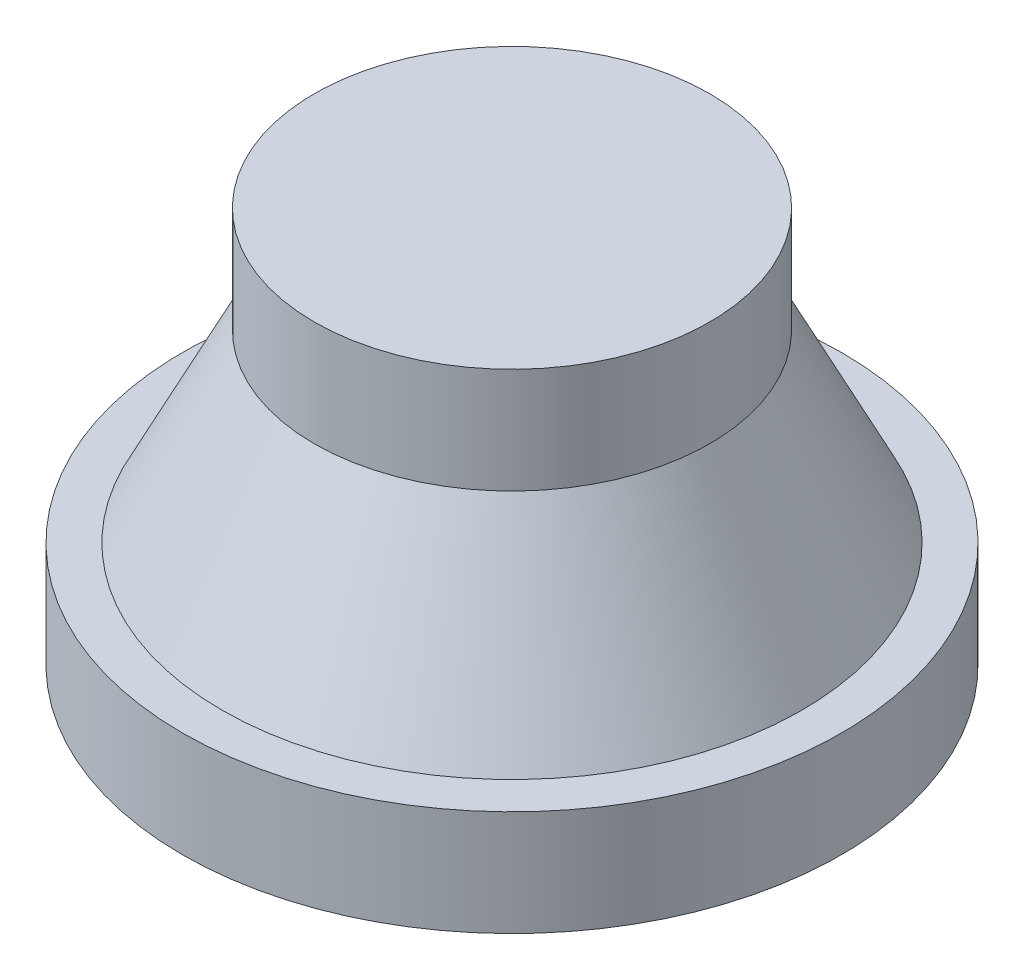
from build123d import *

# Parameters (mm, degrees)
ESBO_O1_R                = 12.5
RESSALTO_EXTRUS_O1_DEPTH = 15


with BuildPart() as part:
    # Esboço1 → Ressalto-extrusão1 (new body)
    with BuildSketch(Plane(origin=(0, 0, 0), x_dir=(1, 0, 0), z_dir=(0, 1, 0))):
        Circle(ESBO_O1_R)
    extrude(amount=RESSALTO_EXTRUS_O1_DEPTH)

    # Esboço2 → Corte-Revolução1 (revolve, cut)
    with BuildSketch(Plane.XY):
        Polygon((-12.5, 4), (-11, 4), (-7.5, 11), (-7.5, 15), (-12.5, 15), align=None)
    revolve(axis=Axis((0, 15, 0), (0, -1, 0)), mode=Mode.SUBTRACT)


solid = part.part
